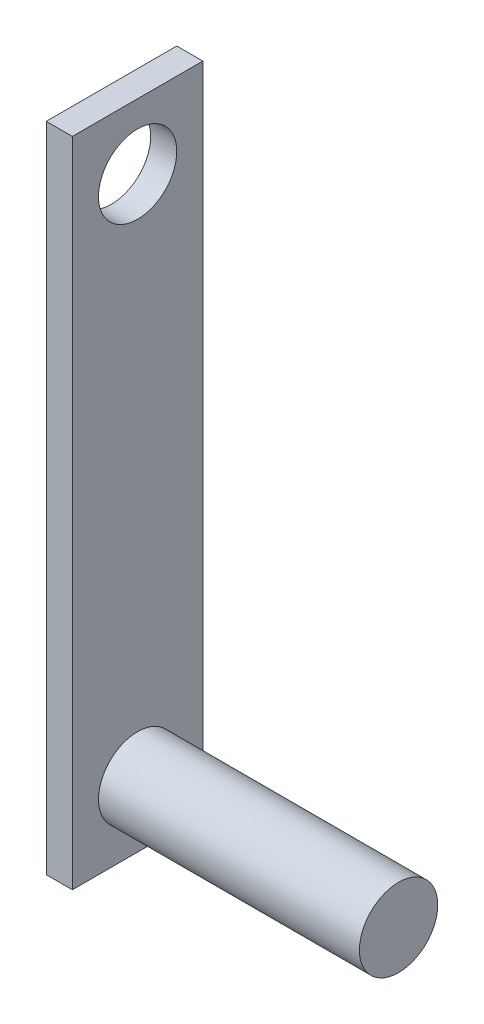
from build123d import *

# Parameters (mm, degrees)
SKETCH1_W           = 10
SKETCH1_H           = 50
BOSS_EXTRUDE1_DEPTH = 2
SKETCH2_R           = 3
CUT_EXTRUDE1_DEPTH  = 2
SKETCH3_R           = 3
BOSS_EXTRUDE2_DEPTH = 20


with BuildPart() as part:
    # Sketch1 → Boss-Extrude1 (new body)
    with BuildSketch(Plane(origin=(0, 0, 0), x_dir=(0, 0, -1), z_dir=(1, 0, 0))):
        Rectangle(SKETCH1_W, SKETCH1_H)
    extrude(amount=BOSS_EXTRUDE1_DEPTH)

    # Sketch2 → Cut-Extrude1 (cut)
    with BuildSketch(Plane(origin=(2, 0, 0), x_dir=(0, 0, -1), z_dir=(1, 0, 0))):
        with Locations((0, 20)):
            Circle(SKETCH2_R)
    extrude(amount=-CUT_EXTRUDE1_DEPTH, mode=Mode.SUBTRACT)

    # Sketch3 → Boss-Extrude2 (add)
    with BuildSketch(Plane(origin=(2, 0, 0), x_dir=(0, 0, -1), z_dir=(1, 0, 0))):
        with Locations((0, -20)):
            Circle(SKETCH3_R)
    extrude(amount=BOSS_EXTRUDE2_DEPTH)


solid = part.part
